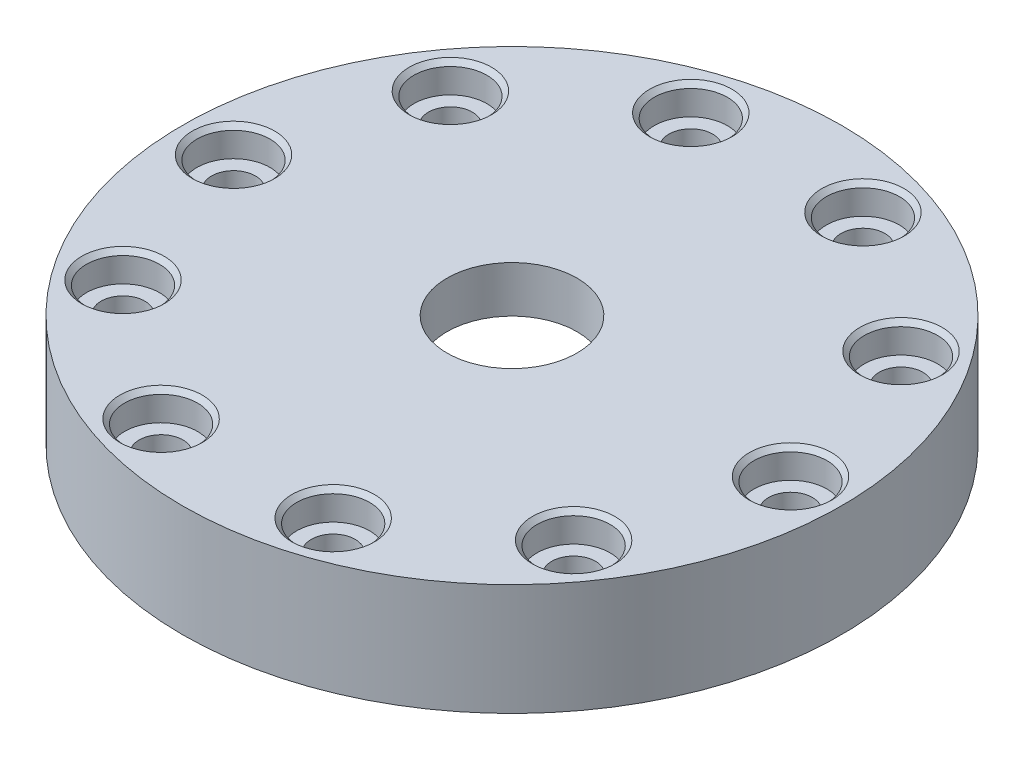
from build123d import *

# Parameters (mm, degrees)
HOLE1_D                      = 6
HOLE1_DEPTH                  = 15.2664
HOLE1_CBORE_D                = 10
HOLE1_CBORE_DEPTH            = 4
CHAMFER1_SIZE                = 0.635
CIRPATTERN1_COUNT            = 10
CHAMFER1_OF_CIRPATTERN1_SIZE = 0.635
FILLET1_R                    = 1.27


with BuildPart() as part:
    # Sketch1 → Revolve1 (revolve)
    with BuildSketch(Plane.XY):
        Polygon((8.89, 0), (45.085, 0), (45.085, -15.2654), (24.13, -15.2654), (24.13, -6.35), (8.89, -6.35), align=None)
    revolve(axis=Axis((0, 0, 0), (0, 1, 0)))

    # Hole1
    with Locations(Plane(origin=(0, 0, 0), x_dir=(1, 0, 0), z_dir=(0, 1, 0))):
        with Locations((38.1, 0)):
            hole1 = CounterBoreHole(HOLE1_D / 2, HOLE1_CBORE_D / 2, HOLE1_CBORE_DEPTH, depth=HOLE1_DEPTH)

    # Chamfer1
    chamfer1_edges = [part.edges().sort_by_distance(p)[0] for p in [
        (33.1, 0, 0),
    ]]
    chamfer(chamfer1_edges, length=CHAMFER1_SIZE)

    # CirPattern1: Hole1 ×10 about axis
    cirpattern1_axis = Axis((0, 0, 0), (0, 1, 0))
    for i in range(1, CIRPATTERN1_COUNT):
        add(hole1.rotate(cirpattern1_axis, i * 360 / CIRPATTERN1_COUNT), mode=Mode.SUBTRACT)

    # Chamfer1 of CirPattern1
    chamfer1_of_cirpattern1_edges = [part.edges().sort_by_distance(p)[0] for p in [
        (26.778462514, 0, -19.455691851),
        (10.228462514, 0, -31.479970689),
        (-10.228462514, 0, -31.479970689),
        (-26.778462514, 0, -19.455691851),
        (-33.1, 0, 0),
        (-26.778462514, 0, 19.455691851),
        (-10.228462514, 0, 31.479970689),
        (10.228462514, 0, 31.479970689),
        (26.778462514, 0, 19.455691851),
    ]]
    chamfer(chamfer1_of_cirpattern1_edges, length=CHAMFER1_OF_CIRPATTERN1_SIZE)

    # Fillet1
    fillet1_edges = [part.edges().sort_by_distance(p)[0] for p in [
        (-24.13, -6.35, 0),
    ]]
    fillet(fillet1_edges, radius=FILLET1_R)


solid = part.part
